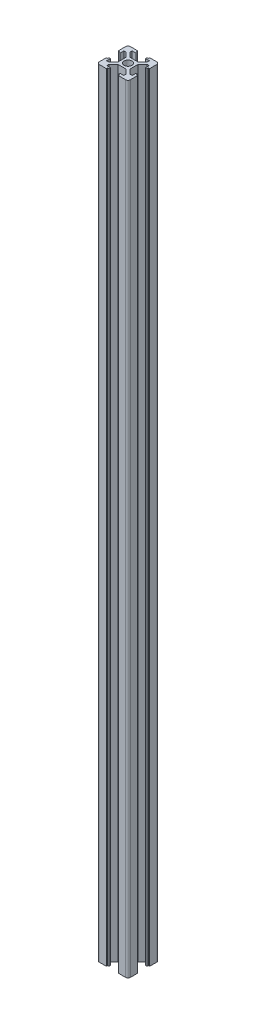
from build123d import *

# Parameters (mm, degrees)
SKETCH1_R           = 2.5
BOSS_EXTRUDE1_DEPTH = 500


with BuildPart() as part:
    # Sketch1 → Boss-Extrude1 (new body)
    with BuildSketch(Plane(origin=(0, 0, 0), x_dir=(1, 0, 0), z_dir=(0, 1, 0))):
        with BuildLine():
            Line((3.9, 10), (8.5, 10))
            ThreePointArc((8.5, 10), (9.560660172, 9.560660172), (10, 8.5))
            Line((10, 8.5), (10, 3.9))
            Line((10, 3.9), (9.2, 3.9))
            Line((9.2, 3.9), (9.2, 3.1))
            Line((9.2, 3.1), (8.2, 3.1))
            Line((8.2, 3.1), (8.2, 5.5))
            Line((8.2, 5.5), (6.77, 5.5))
            Line((6.77, 5.5), (3.9, 2.63))
            Line((3.9, 2.63), (3.9, 0))
            Line((3.9, 0), (3.9, -2.63))
            Line((3.9, -2.63), (6.77, -5.5))
            Line((6.77, -5.5), (8.2, -5.5))
            Line((8.2, -5.5), (8.2, -3.1))
            Line((8.2, -3.1), (9.2, -3.1))
            Line((9.2, -3.1), (9.2, -3.9))
            Line((9.2, -3.9), (10, -3.9))
            Line((10, -3.9), (10, -8.5))
            ThreePointArc((10, -8.5), (9.560660172, -9.560660172), (8.5, -10))
            Line((8.5, -10), (3.9, -10))
            Line((3.9, -10), (3.9, -9.2))
            Line((3.9, -9.2), (3.1, -9.2))
            Line((3.1, -9.2), (3.1, -8.2))
            Line((3.1, -8.2), (5.5, -8.2))
            Line((5.5, -8.2), (5.5, -6.77))
            Line((5.5, -6.77), (2.63, -3.9))
            Line((2.63, -3.9), (0, -3.9))
            Line((0, -3.9), (-2.63, -3.9))
            Line((-2.63, -3.9), (-5.5, -6.77))
            Line((-5.5, -6.77), (-5.5, -8.2))
            Line((-5.5, -8.2), (-3.1, -8.2))
            Line((-3.1, -8.2), (-3.1, -9.2))
            Line((-3.1, -9.2), (-3.9, -9.2))
            Line((-3.9, -9.2), (-3.9, -10))
            Line((-3.9, -10), (-8.5, -10))
            ThreePointArc((-8.5, -10), (-9.560660172, -9.560660172), (-10, -8.5))
            Line((-10, -8.5), (-10, -3.9))
            Line((-10, -3.9), (-9.2, -3.9))
            Line((-9.2, -3.9), (-9.2, -3.1))
            Line((-9.2, -3.1), (-8.2, -3.1))
            Line((-8.2, -3.1), (-8.2, -5.5))
            Line((-8.2, -5.5), (-6.77, -5.5))
            Line((-6.77, -5.5), (-3.9, -2.63))
            Line((-3.9, -2.63), (-3.9, 0))
            Line((-3.9, 0), (-3.9, 2.63))
            Line((-3.9, 2.63), (-6.77, 5.5))
            Line((-6.77, 5.5), (-8.2, 5.5))
            Line((-8.2, 5.5), (-8.2, 3.1))
            Line((-8.2, 3.1), (-9.2, 3.1))
            Line((-9.2, 3.1), (-9.2, 3.9))
            Line((-9.2, 3.9), (-10, 3.9))
            Line((-10, 3.9), (-10, 8.5))
            ThreePointArc((-10, 8.5), (-9.560660172, 9.560660172), (-8.5, 10))
            Line((-8.5, 10), (-3.9, 10))
            Line((-3.9, 10), (-3.9, 9.2))
            Line((-3.9, 9.2), (-3.1, 9.2))
            Line((-3.1, 9.2), (-3.1, 8.2))
            Line((-3.1, 8.2), (-5.5, 8.2))
            Line((-5.5, 8.2), (-5.5, 6.77))
            Line((-5.5, 6.77), (-2.63, 3.9))
            Line((-2.63, 3.9), (2.63, 3.9))
            Line((2.63, 3.9), (5.5, 6.77))
            Line((5.5, 6.77), (5.5, 8.2))
            Line((5.5, 8.2), (3.1, 8.2))
            Line((3.1, 8.2), (3.1, 9.2))
            Line((3.1, 9.2), (3.9, 9.2))
            Line((3.9, 9.2), (3.9, 10))
        make_face()
        Circle(SKETCH1_R, mode=Mode.SUBTRACT)
    extrude(amount=BOSS_EXTRUDE1_DEPTH)


solid = part.part
